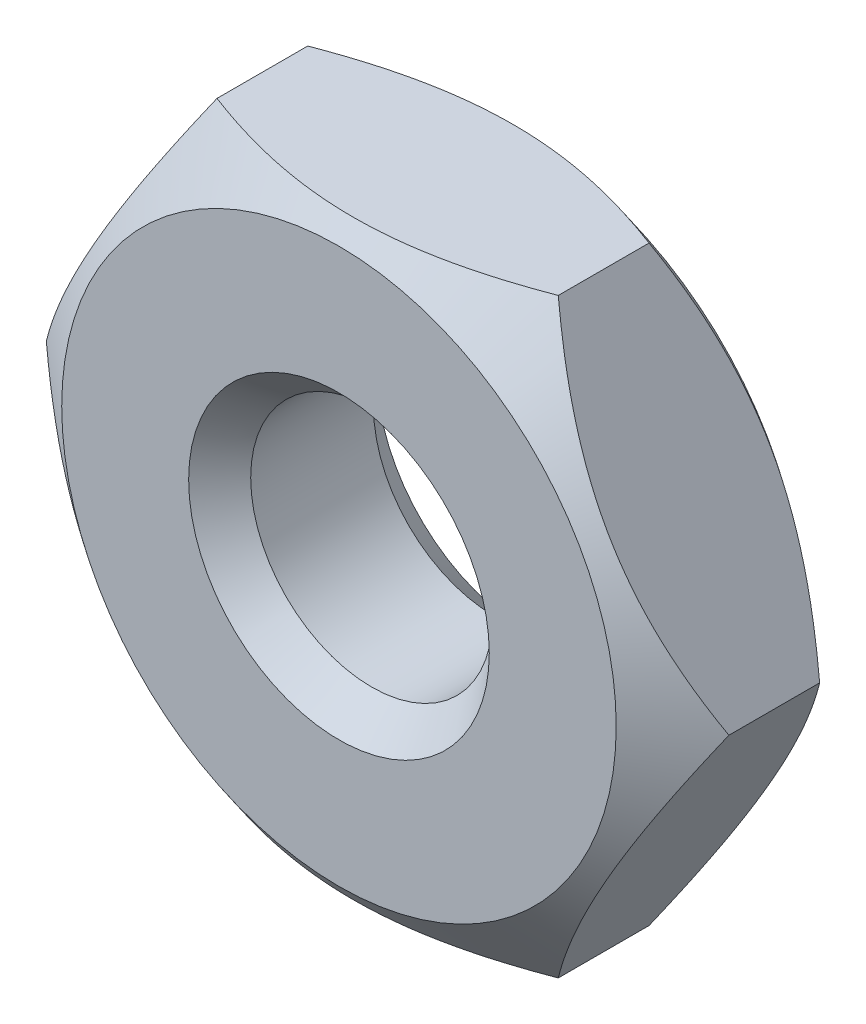
from build123d import *

# Parameters (mm, degrees)
SKETCH1_R      = 1.125
EXTRUDE1_DEPTH = 0.875


with BuildPart() as part:
    # Sketch1 → Extrude1 (new body, symmetric)
    with BuildSketch(Plane.XY):
        Polygon((3.175426481, 0), (1.58771324, 2.75), (-1.58771324, 2.75), (-3.175426481, 0), (-1.58771324, -2.75), (1.58771324, -2.75), align=None)
        Circle(SKETCH1_R, mode=Mode.SUBTRACT)
    extrude(amount=EXTRUDE1_DEPTH, both=True)

    # Sketch2 → Cut-Revolve1 (revolve, cut)
    with BuildSketch(Plane(origin=(0, 0, 0), x_dir=(1, 0, 0), z_dir=(0, 1, 0))):
        Polygon((3.175426481, 0.875), (3.175426481, 0.422248701), (2.579675658, 0.875), align=None)
        Polygon((3.175426481, -0.875), (3.175426481, -0.422248701), (2.579675658, -0.875), align=None)
        Polygon((1.042426481, 0.875), (1.398698822, 0.875), (1.042426481, 0.47968772), align=None)
        Polygon((1.042426481, -0.875), (1.398698822, -0.875), (1.042426481, -0.47968772), align=None)
    revolve(axis=Axis((0, 0, -0.875), (0, 0, 1)), mode=Mode.SUBTRACT)


solid = part.part
